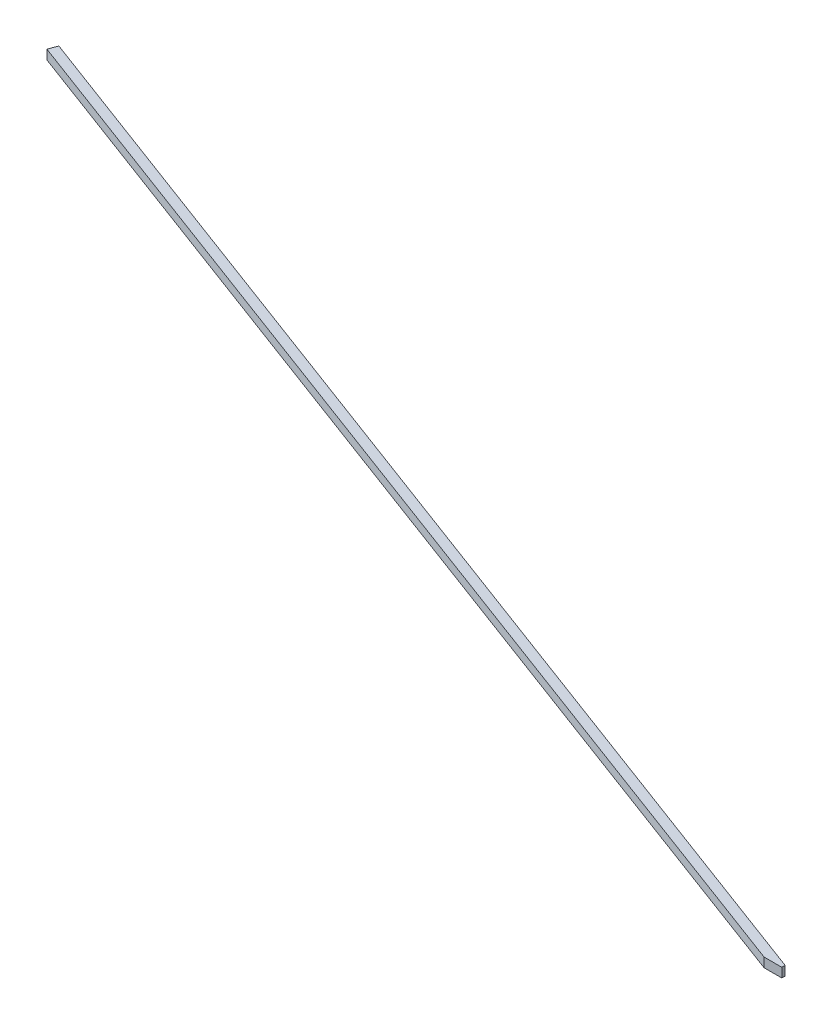
from build123d import *

# Parameters (mm, degrees)
BOSS_EXTRUDE1_DEPTH   = 3.175
BOSS_EXTRUDE1_2_DEPTH = 3.175
SKETCH2_W             = 3.175
SKETCH2_H             = 36.35
BOSS_EXTRUDE2_DEPTH   = 3.175
SKETCH3_W             = 3.175
SKETCH3_H             = 3.175
BOSS_EXTRUDE8_DEPTH   = 423.175
BOSS_EXTRUDE8_2_DEPTH = 423.175
SKETCH4_W             = 3.175
SKETCH4_H             = 36.35
CUT_EXTRUDE1_DEPTH    = 427.326430831
CUT_EXTRUDE5_DEPTH    = 408.294257878
BOSS_EXTRUDE9_DEPTH   = 3.175
SKETCH8_R             = 22.246551504
CUT_EXTRUDE6_DEPTH    = 30
SKETCH9_W             = 3.175
SKETCH9_H             = 3.175
BOSS_EXTRUDE10_DEPTH  = 9.525
SKETCH10_W            = 3.036361865
SKETCH10_H            = 1.134211297
CUT_EXTRUDE7_DEPTH    = 10


with BuildPart() as part:
    # Sketch1 → Boss-Extrude1 (new body)
    with BuildSketch(Plane.XY):
        Polygon((15, 45), (405, 45), (405, 48.175), (18.175, 48.175), (-18.175, 48.175), (-18.175, 45), (-15, 45), align=None)
    extrude(amount=BOSS_EXTRUDE1_DEPTH)



with BuildPart() as body_2:
    # Sketch1 → Boss-Extrude1 2 (new body)
    with BuildSketch(Plane.XY):
        Polygon((-18.175, 15), (-15, 15), (15, 15), (405, 15), (405, 11.825), (18.175, 11.825), (-18.175, 11.825), align=None)
    extrude(amount=BOSS_EXTRUDE1_2_DEPTH)


with BuildPart() as part_1:
    add(part.part)

    add(body_2.part)  # Boss-Extrude2 merges body 2
    # Sketch2 → Boss-Extrude2 (add)
    with BuildSketch(Plane.XY.offset(3.175)):
        with Locations((-16.5875, 30)):
            Rectangle(SKETCH2_W, SKETCH2_H)
        Polygon((15, 11.825), (22.589723325, 11.825), (112.5, 46.473699254), (112.5, 12.285600704), (112.5, 11.825), (120.025102002, 11.825), (208.4125, 46.469905429), (208.4125, 11.825), (215.937602002, 11.825), (304.325, 46.469905429), (304.325, 11.825), (311.914723325, 11.825), (401.825, 46.473699254), (401.825, 11.825), (405, 11.825), (405, 48.175), (397.410276675, 48.175), (307.5, 13.526300746), (307.5, 48.175), (299.974897998, 48.175), (211.5875, 13.530094571), (211.5875, 48.175), (204.062397998, 48.175), (115.675, 13.530094571), (115.675, 48.175), (108.085276675, 48.175), (18.175, 13.526300746), (18.175, 48.175), (15, 48.175), align=None)
    extrude(amount=BOSS_EXTRUDE2_DEPTH)

    # Sketch4 → Cut-Extrude1 (cut, through all)
    with BuildSketch(Plane(origin=(405, 0, 0), x_dir=(0, 0, -1), z_dir=(1, 0, 0))):
        with Locations((-1.5875, 30)):
            Rectangle(SKETCH4_W, SKETCH4_H)
    extrude(amount=-CUT_EXTRUDE1_DEPTH, mode=Mode.SUBTRACT)


with BuildPart() as body_2_2:
    # Sketch3 → Boss-Extrude8 (new body)
    with BuildSketch(Plane(origin=(405, 0, 0), x_dir=(0, 0, -1), z_dir=(1, 0, 0))):
        with Locations((-4.7625, 49.7625)):
            Rectangle(SKETCH3_W, SKETCH3_H)
    extrude(amount=-BOSS_EXTRUDE8_DEPTH)


with BuildPart() as body_3:
    # Sketch3 → Boss-Extrude8 2 (new body)
    with BuildSketch(Plane(origin=(405, 0, 0), x_dir=(0, 0, -1), z_dir=(1, 0, 0))):
        with Locations((-4.7625, 10.2375)):
            Rectangle(SKETCH3_W, SKETCH3_H)
    extrude(amount=-BOSS_EXTRUDE8_2_DEPTH)


with BuildPart() as cut_extrude1_piece_1:
    # of the separate pieces the step leaves, piece 1, a body of its own (cut_extrude1_pieces)
    add(part_1.part.solids().sort_by_distance((401.825, 11.825, 3.175))[0])


with BuildPart() as cut_extrude1_piece_2:
    # of the separate pieces the step leaves, piece 2, a body of its own (cut_extrude1_pieces)
    add(part_1.part.solids().sort_by_distance((-15, 48.175, 3.175))[0])


with BuildPart() as cut_extrude5_tool:
    # Sketch5 → Cut-Extrude5 (new, through all)
    with BuildSketch(Plane.XZ.offset(-8.65)):
        Polygon((-18.175, 6.35), (-18.175, 3.175), (381.963638135, 3.175), (390.463332101, 6.35), align=None)
        Polygon((405, 6.35), (399.536667899, 6.35), (391.036973934, 3.175), (405, 3.175), align=None)
    extrude(amount=-CUT_EXTRUDE5_DEPTH)


with BuildPart() as body_2_2_1:
    add(body_2_2.part)

    # Cut-Extrude5: cut by cut_extrude5_tool
    add(cut_extrude5_tool.part, mode=Mode.SUBTRACT)


with BuildPart() as body_3_1:
    add(body_3.part)

    # Cut-Extrude5: cut by cut_extrude5_tool
    add(cut_extrude5_tool.part, mode=Mode.SUBTRACT)

    # Sketch5_3 → Boss-Extrude9 (add)
    with BuildSketch(Plane.XZ.offset(-8.65)):
        with BuildLine():
            Line((391.036973934, 3.175), (381.963638135, 3.175))
            Line((381.963638135, 3.175), (13.554929678, -134.441442909))
            ThreePointArc((13.554929678, -134.441442909), (14.260668904, -135.872458965), (14.665946091, -137.415710471))
            Line((14.665946091, -137.415710471), (391.036973934, 3.175))
        make_face()
        with BuildLine():
            ThreePointArc((14.665946091, -137.415710471), (14.260668904, -135.872458965), (13.554929678, -134.441442909))
            Line((13.554929678, -134.441442909), (9.243759355, -136.051849805))
            Line((9.243759355, -136.051849805), (10.354775769, -139.026117367))
            Line((10.354775769, -139.026117367), (14.665946091, -137.415710471))
        make_face()
    extrude(amount=-BOSS_EXTRUDE9_DEPTH)

    # Sketch9 → Boss-Extrude10 (add)
    with BuildSketch(Plane(origin=(-36.486342691, 0, -13.62921283), x_dir=(-0.34992642955188064, 0, 0.93677718476758), z_dir=(-0.93677718476758, 0, -0.34992642955188064))):
        with Locations((-132.27240455, 10.2375)):
            Rectangle(SKETCH9_W, SKETCH9_H)
    extrude(amount=BOSS_EXTRUDE10_DEPTH)

    # Sketch10 → Cut-Extrude7 (cut)
    with BuildSketch(Plane.XZ.offset(-8.65)):
        with Locations((398.018486967, 5.782894352)):
            Rectangle(SKETCH10_W, SKETCH10_H)
    extrude(amount=-CUT_EXTRUDE7_DEPTH, mode=Mode.SUBTRACT)


with BuildPart() as cut_extrude1_piece_1_1:
    add(cut_extrude1_piece_1.part)

    # Cut-Extrude5: cut by cut_extrude5_tool
    add(cut_extrude5_tool.part, mode=Mode.SUBTRACT)


with BuildPart() as cut_extrude1_piece_2_1:
    add(cut_extrude1_piece_2.part)

    # Cut-Extrude5: cut by cut_extrude5_tool
    add(cut_extrude5_tool.part, mode=Mode.SUBTRACT)


with BuildPart() as cut_extrude6_tool:
    # Sketch8 → Cut-Extrude6 (new body)
    with BuildSketch(Plane(origin=(0, 51.35, 0), x_dir=(1, 0, 0), z_dir=(0, 1, 0))):
        with Locations((390.031158892, -4.957539076)):
            Circle(SKETCH8_R)
    extrude(amount=-CUT_EXTRUDE6_DEPTH)


with BuildPart() as body_2_2_2:
    add(body_2_2_1.part)

    # Cut-Extrude6: cut by cut_extrude6_tool
    add(cut_extrude6_tool.part, mode=Mode.SUBTRACT)


with BuildPart() as cut_extrude1_piece_1_2:
    add(cut_extrude1_piece_1_1.part)

    # Cut-Extrude6: cut by cut_extrude6_tool
    add(cut_extrude6_tool.part, mode=Mode.SUBTRACT)


solid = body_3_1.part
